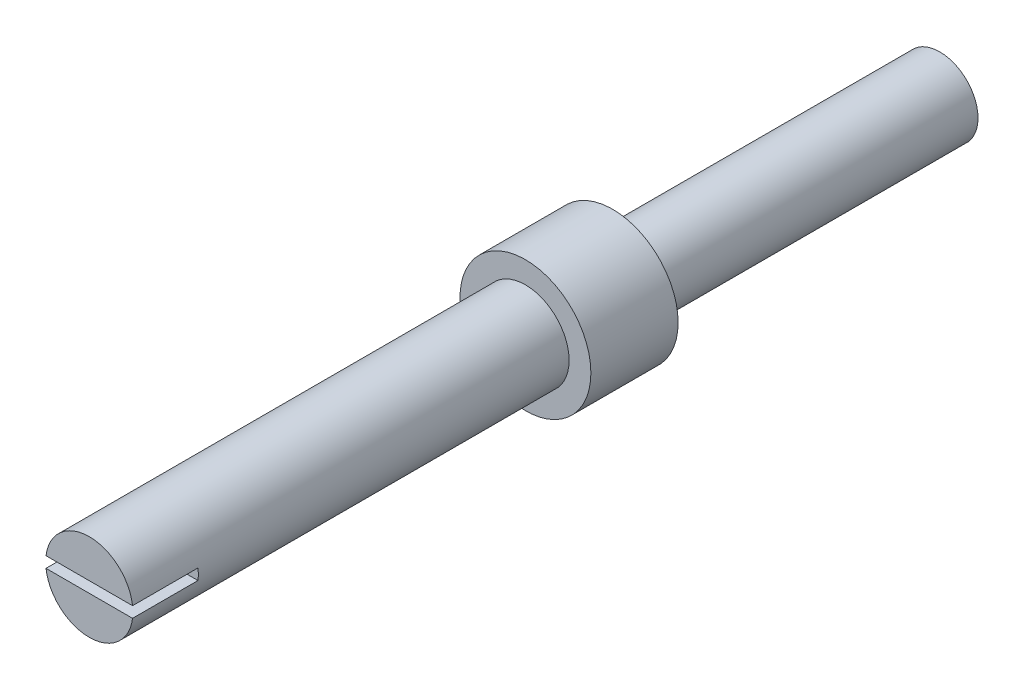
from build123d import *

# Parameters (mm, degrees)
SKETCH_1_R          = 3
EXTRUDE_1_DEPTH     = 4
SKETCH_2_R          = 2
EXTRUDE_2_DEPTH     = 20
SKETCH_3_R          = 1.75
EXTRUDE_3_DEPTH     = 15
SKETCH_4_W          = 4.461198183
SKETCH_4_H          = 0.5
CUT_EXTRUDE_1_DEPTH = 3


with BuildPart() as part:
    # 스케치1 → 보스-돌출1 (new body)
    with BuildSketch(Plane.XY):
        Circle(SKETCH_1_R)
    extrude(amount=EXTRUDE_1_DEPTH)

    # 스케치2 → 보스-돌출2 (add)
    with BuildSketch(Plane.XY.offset(4)):
        Circle(SKETCH_2_R)
    extrude(amount=EXTRUDE_2_DEPTH)

    # 스케치3 → 보스-돌출3 (add)
    with BuildSketch(Plane(origin=(0, 0, 0), x_dir=(-1, 0, 0), z_dir=(0, 0, -1))):
        Circle(SKETCH_3_R)
    extrude(amount=EXTRUDE_3_DEPTH)

    # 스케치4 → 컷-돌출1 (cut)
    with BuildSketch(Plane.XY.offset(24)):
        with Locations((-0.011637909, 0)):
            Rectangle(SKETCH_4_W, SKETCH_4_H)
    extrude(amount=-CUT_EXTRUDE_1_DEPTH, mode=Mode.SUBTRACT)


solid = part.part
